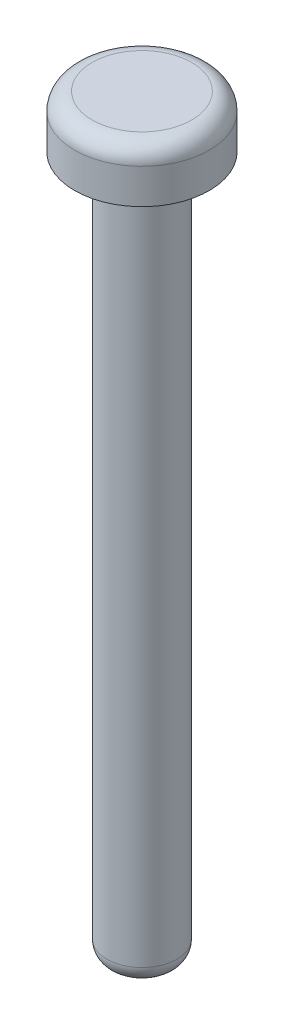
from build123d import *

# Parameters (mm, degrees)
SKETCH1_R           = 2
BOSS_EXTRUDE1_DEPTH = 40
SKETCH2_R           = 3.85
BOSS_EXTRUDE2_DEPTH = 3
FILLET1_R           = 1
FILLET2_R           = 1


with BuildPart() as part:
    # Sketch1 → Boss-Extrude1 (new body)
    with BuildSketch(Plane(origin=(0, 0, 0), x_dir=(1, 0, 0), z_dir=(0, 1, 0))):
        Circle(SKETCH1_R)
    extrude(amount=BOSS_EXTRUDE1_DEPTH)

    # Sketch2 → Boss-Extrude2 (add)
    with BuildSketch(Plane(origin=(0, 40, 0), x_dir=(1, 0, 0), z_dir=(0, 1, 0))):
        Circle(SKETCH2_R)
    extrude(amount=BOSS_EXTRUDE2_DEPTH)

    # Fillet1
    fillet1_edges = [part.edges().sort_by_distance(p)[0] for p in [
        (-3.85, 43, 0),
    ]]
    fillet(fillet1_edges, radius=FILLET1_R)

    # Fillet2
    fillet2_edges = [part.edges().sort_by_distance(p)[0] for p in [
        (-2, 0, 0),
        (-2, 40, 0),
    ]]
    fillet(fillet2_edges, radius=FILLET2_R)


solid = part.part
